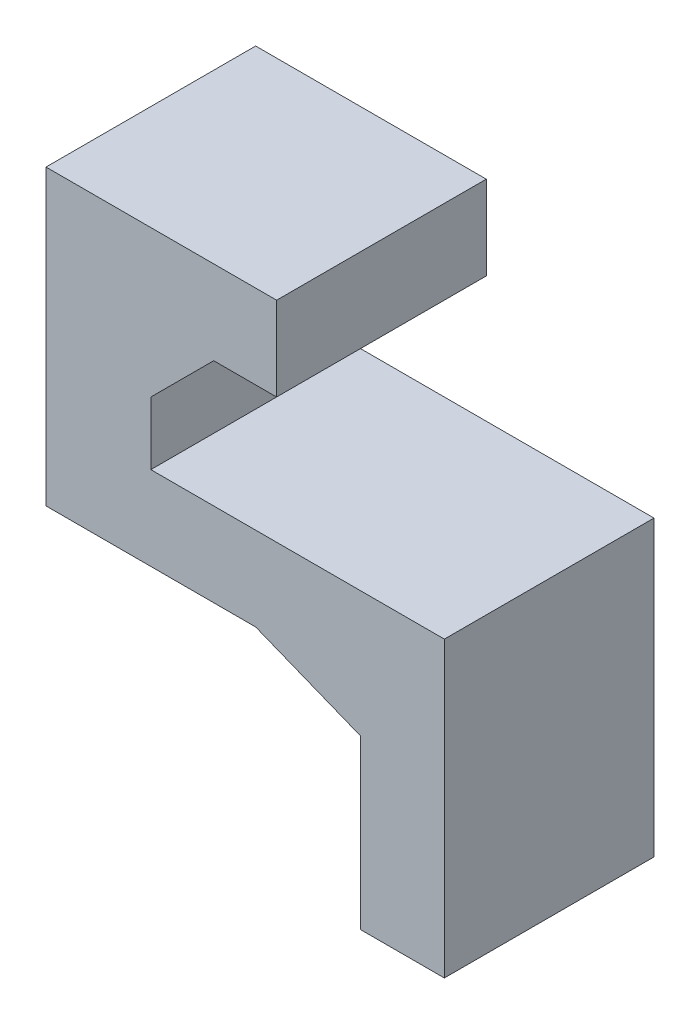
from build123d import *

# Parameters (mm, degrees)
BOSS_EXTRU_1_DEPTH = 50
BOSS_EXTRU_2_DEPTH = 50
BOSS_EXTRU_3_DEPTH = 50


with BuildPart() as part:
    # Esquisse1 → Boss.-Extru.1 (new body)
    with BuildSketch(Plane.XY):
        Polygon((-40, 100), (-70, 100), (-70, 70), (0, 70), (0, 0), (-20, 0), (-20, 50), (-95, 50), (-95, 120), (-40, 120), align=None)
    extrude(amount=-BOSS_EXTRU_1_DEPTH)

    # Esquisse3 → Boss.-Extru.2 (add)
    with BuildSketch(Plane.XY):
        Polygon((-45, 50), (-20, 40), (-20, 50), align=None)
    extrude(amount=-BOSS_EXTRU_2_DEPTH)

    # Esquisse3_4 → Boss.-Extru.3 (add)
    with BuildSketch(Plane.XY):
        Polygon((-70, 100), (-70, 85), (-55, 100), align=None)
    extrude(amount=-BOSS_EXTRU_3_DEPTH)


solid = part.part
